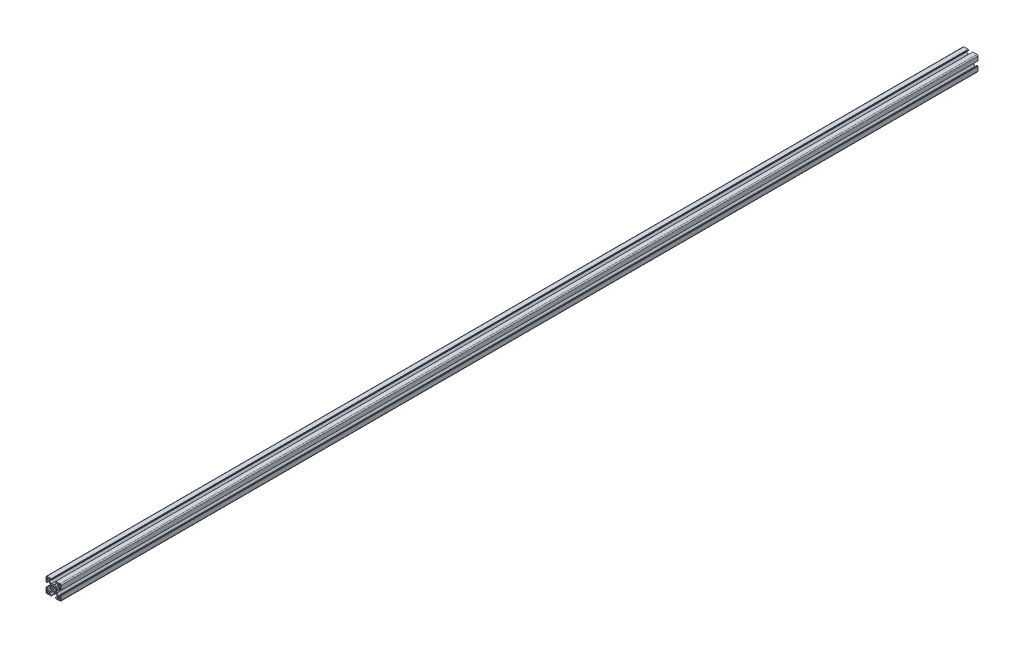
from build123d import *

# Parameters (mm, degrees)
BOSS_EXTRUDE1_DEPTH     = 1828.8
CUT_EXTRUDE1_DEPTH      = 1
CUT_EXTRUDE1_DEPTH_BACK = 1829.8


with BuildPart() as part:
    # Sketch4 → Boss-Extrude1 (new body)
    with BuildSketch(Plane.XY):
        with BuildLine():
            Line((0, -5.45), (0.655464476, -6))
            Line((0.655464476, -6), (4.504469158, -6))
            Line((4.504469158, -6), (8.25, -9.745530842))
            Line((8.25, -9.745530842), (8.25, -12.885))
            Line((8.25, -12.885), (4, -12.885))
            Line((4, -12.885), (4, -14.45))
            Line((4, -14.45), (4.55, -14.45))
            Line((4.55, -14.45), (4.55, -15))
            Line((4.55, -15), (12.885, -15))
            ThreePointArc((12.885, -15), (14.380530842, -14.380530842), (15, -12.885))
            Line((15, -12.885), (15, -4.55))
            Line((15, -4.55), (14.45, -4.55))
            Line((14.45, -4.55), (14.45, -4))
            Line((14.45, -4), (12.885, -4))
            Line((12.885, -4), (12.885, -8.25))
            Line((12.885, -8.25), (9.745530842, -8.25))
            Line((9.745530842, -8.25), (6, -4.504469158))
            Line((6, -4.504469158), (6, -0.655464476))
            Line((6, -0.655464476), (5.45, 0))
            Line((5.45, 0), (3.5, 0))
            ThreePointArc((3.5, 0), (3.371433308, -0.939913534), (2.995178599, -1.81077474))
            Line((2.995178599, -1.81077474), (4.675743591, -3.491339732))
            Line((4.675743591, -3.491339732), (3.491339732, -4.675743591))
            Line((3.491339732, -4.675743591), (1.81077474, -2.995178599))
            ThreePointArc((1.81077474, -2.995178599), (0.939913534, -3.371433308), (0, -3.5))
            Line((0, -3.5), (0, -5.45))
        make_face()
        with BuildLine():
            Line((9.375, -10.365), (9.375, -12.885))
            ThreePointArc((9.375, -12.885), (9.664964287, -13.585035713), (10.365, -13.875))
            Line((10.365, -13.875), (12.885, -13.875))
            ThreePointArc((12.885, -13.875), (13.585035713, -13.585035713), (13.875, -12.885))
            Line((13.875, -12.885), (13.875, -10.365))
            ThreePointArc((13.875, -10.365), (13.585035713, -9.664964287), (12.885, -9.375))
            Line((12.885, -9.375), (10.365, -9.375))
            ThreePointArc((10.365, -9.375), (9.664964287, -9.664964287), (9.375, -10.365))
        make_face(mode=Mode.SUBTRACT)
    extrude(amount=BOSS_EXTRUDE1_DEPTH)

    # Mirror1: part across plane


with BuildPart() as part_1:
    add(part.part)
    add(part.part.mirror(Plane(origin=(0, 0, 0), x_dir=(0, 0, 1), z_dir=(1, 0, 0))))

    # Mirror2: part across plane


with BuildPart() as part_2:
    add(part_1.part)
    add(part_1.part.mirror(Plane.ZX))

    # Sketch5 → Cut-Extrude1 (cut, two sides)
    with BuildSketch(Plane.XY.offset(1828.8)) as cut_extrude1_sk:
        Polygon((-5.675, 12.885), (-5.4, 13.16), (-5.125, 12.885), align=None)
    extrude(amount=CUT_EXTRUDE1_DEPTH, mode=Mode.SUBTRACT)
    extrude(cut_extrude1_sk.sketch, amount=-CUT_EXTRUDE1_DEPTH_BACK, mode=Mode.SUBTRACT)


solid = part_2.part
